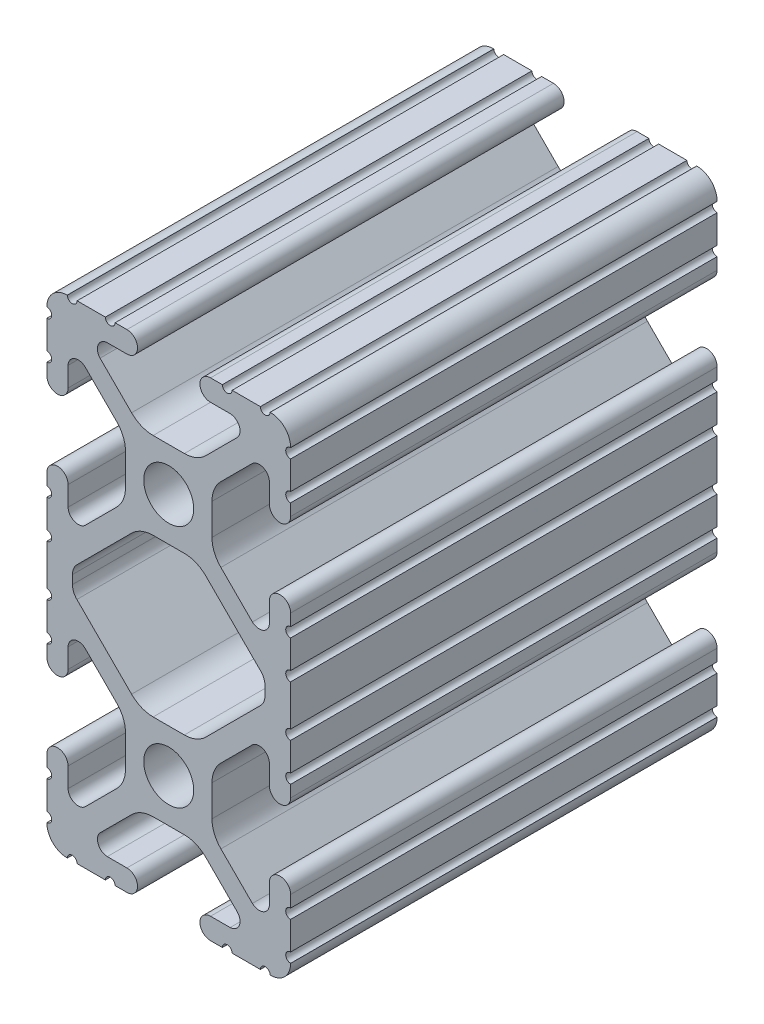
from build123d import *

# Parameters (mm, degrees)
SKETCH1_R      = 2.6035
EXTRUDE1_DEPTH = 44.45


with BuildPart() as part:
    # Sketch1 → Extrude1 (new body)
    with BuildSketch(Plane.XY):
        with BuildLine():
            Line((925.030031307, 602.850527299), (925.030031307, 605.796927299))
            ThreePointArc((925.030031307, 605.796927299), (924.522031307, 606.304927299), (925.030031307, 606.812927299))
            Line((925.030031307, 606.812927299), (925.030031307, 608.044827299))
            ThreePointArc((925.030031307, 608.044827299), (923.925131307, 609.149727299), (922.820231307, 608.044827299))
            Line((922.820231307, 608.044827299), (922.820231307, 605.99597822))
            ThreePointArc((922.820231307, 605.99597822), (922.173798087, 605.055266469), (921.048395335, 605.245747838))
            Line((921.048395335, 605.245747838), (917.764377722, 608.529666789))
            ThreePointArc((917.764377722, 608.529666789), (917.076099637, 609.559722614), (916.834408027, 610.774764544))
            Line((916.834408027, 610.774764544), (916.834408027, 614.027171862))
            ThreePointArc((916.834408027, 614.027171862), (917.076098205, 615.242210334), (917.764372429, 616.272264325))
            Line((917.764372429, 616.272264325), (921.048175959, 619.555984679))
            ThreePointArc((921.048175959, 619.555984679), (922.176497414, 619.74525718), (922.820231307, 618.799455901))
            Line((922.820231307, 618.799455901), (922.820231307, 616.757027299))
            ThreePointArc((922.820231307, 616.757027299), (923.925131307, 615.652127299), (925.030031307, 616.757027299))
            Line((925.030031307, 616.757027299), (925.030031307, 617.988927299))
            ThreePointArc((925.030031307, 617.988927299), (924.522031307, 618.496927299), (925.030031307, 619.004927299))
            Line((925.030031307, 619.004927299), (925.030031307, 621.951327299))
            ThreePointArc((925.030031307, 621.951327299), (924.522031307, 622.459327299), (925.030031307, 622.967327299))
            Line((925.030031307, 622.967327299), (925.030031307, 622.992727299))
            ThreePointArc((925.030031307, 622.992727299), (924.412553823, 624.483449815), (922.921831307, 625.100927299))
            Line((922.921831307, 625.100927299), (922.896431307, 625.100927299))
            ThreePointArc((922.896431307, 625.100927299), (922.388431307, 624.592927299), (921.880431307, 625.100927299))
            Line((921.880431307, 625.100927299), (918.934031307, 625.100927299))
            ThreePointArc((918.934031307, 625.100927299), (918.426031307, 624.592927299), (917.918031307, 625.100927299))
            Line((917.918031307, 625.100927299), (916.686131307, 625.100927299))
            ThreePointArc((916.686131307, 625.100927299), (915.581231307, 623.996027299), (916.686131307, 622.891127299))
            Line((916.686131307, 622.891127299), (918.734980386, 622.891127299))
            ThreePointArc((918.734980386, 622.891127299), (919.675692137, 622.244694079), (919.485210768, 621.119291326))
            Line((919.485210768, 621.119291326), (916.201291817, 617.835273713))
            ThreePointArc((916.201291817, 617.835273713), (915.171235992, 617.146995629), (913.956194062, 616.905304018))
            Line((913.956194062, 616.905304018), (910.703786744, 616.905304018))
            ThreePointArc((910.703786744, 616.905304018), (909.488748272, 617.146994197), (908.458694281, 617.835268421))
            Line((908.458694281, 617.835268421), (905.174973927, 621.11907195))
            ThreePointArc((905.174973927, 621.11907195), (904.985701426, 622.247393405), (905.931502705, 622.891127299))
            Line((905.931502705, 622.891127299), (907.973931307, 622.891127299))
            ThreePointArc((907.973931307, 622.891127299), (909.078831307, 623.996027299), (907.973931307, 625.100927299))
            Line((907.973931307, 625.100927299), (906.742031307, 625.100927299))
            ThreePointArc((906.742031307, 625.100927299), (906.234031307, 624.592927299), (905.726031307, 625.100927299))
            Line((905.726031307, 625.100927299), (902.779631307, 625.100927299))
            ThreePointArc((902.779631307, 625.100927299), (902.271631307, 624.592927299), (901.763631307, 625.100927299))
            Line((901.763631307, 625.100927299), (901.738231307, 625.100927299))
            ThreePointArc((901.738231307, 625.100927299), (900.247508791, 624.483449815), (899.630031307, 622.992727299))
            Line((899.630031307, 622.992727299), (899.630031307, 622.967327299))
            ThreePointArc((899.630031307, 622.967327299), (900.138031307, 622.459327299), (899.630031307, 621.951327299))
            Line((899.630031307, 621.951327299), (899.630031307, 619.004927299))
            ThreePointArc((899.630031307, 619.004927299), (900.138031307, 618.496927299), (899.630031307, 617.988927299))
            Line((899.630031307, 617.988927299), (899.630031307, 616.757027299))
            ThreePointArc((899.630031307, 616.757027299), (900.734931307, 615.652127299), (901.839831307, 616.757027299))
            Line((901.839831307, 616.757027299), (901.839831307, 618.805876378))
            ThreePointArc((901.839831307, 618.805876378), (902.486264527, 619.746588129), (903.61166728, 619.55610676))
            Line((903.61166728, 619.55610676), (906.895684893, 616.272187809))
            ThreePointArc((906.895684893, 616.272187809), (907.583962977, 615.242131983), (907.825654588, 614.027090054))
            Line((907.825654588, 614.027090054), (907.825654588, 610.774682736))
            ThreePointArc((907.825654588, 610.774682736), (907.583964409, 609.559644263), (906.895690185, 608.529590273))
            Line((906.895690185, 608.529590273), (903.611886656, 605.245869918))
            ThreePointArc((903.611886656, 605.245869918), (902.483565201, 605.056597418), (901.839831307, 606.002398697))
            Line((901.839831307, 606.002398697), (901.839831307, 608.044827299))
            ThreePointArc((901.839831307, 608.044827299), (900.734931307, 609.149727299), (899.630031307, 608.044827299))
            Line((899.630031307, 608.044827299), (899.630031307, 606.812927299))
            ThreePointArc((899.630031307, 606.812927299), (900.138031307, 606.304927299), (899.630031307, 605.796927299))
            Line((899.630031307, 605.796927299), (899.630031307, 602.850527299))
            ThreePointArc((899.630031307, 602.850527299), (900.138031307, 602.342527299), (899.630031307, 601.834527299))
            Line((899.630031307, 601.834527299), (899.630031307, 597.567327299))
            ThreePointArc((899.630031307, 597.567327299), (900.138031307, 597.059327299), (899.630031307, 596.551327299))
            Line((899.630031307, 596.551327299), (899.630031307, 593.604927299))
            ThreePointArc((899.630031307, 593.604927299), (900.138031307, 593.096927299), (899.630031307, 592.588927299))
            Line((899.630031307, 592.588927299), (899.630031307, 591.357027299))
            ThreePointArc((899.630031307, 591.357027299), (900.734931307, 590.252127299), (901.839831307, 591.357027299))
            Line((901.839831307, 591.357027299), (901.839831307, 593.405876378))
            ThreePointArc((901.839831307, 593.405876378), (902.486264527, 594.346588129), (903.61166728, 594.15610676))
            Line((903.61166728, 594.15610676), (906.895684893, 590.872187809))
            ThreePointArc((906.895684893, 590.872187809), (907.583962977, 589.842131983), (907.825654588, 588.627090054))
            Line((907.825654588, 588.627090054), (907.825654588, 585.374682736))
            ThreePointArc((907.825654588, 585.374682736), (907.583964409, 584.159644263), (906.895690185, 583.129590273))
            Line((906.895690185, 583.129590273), (903.611886656, 579.845869918))
            ThreePointArc((903.611886656, 579.845869918), (902.483565201, 579.656597418), (901.839831307, 580.602398697))
            Line((901.839831307, 580.602398697), (901.839831307, 582.644827299))
            ThreePointArc((901.839831307, 582.644827299), (900.734931307, 583.749727299), (899.630031307, 582.644827299))
            Line((899.630031307, 582.644827299), (899.630031307, 581.412927299))
            ThreePointArc((899.630031307, 581.412927299), (900.138031307, 580.904927299), (899.630031307, 580.396927299))
            Line((899.630031307, 580.396927299), (899.630031307, 577.450527299))
            ThreePointArc((899.630031307, 577.450527299), (900.138031307, 576.942527299), (899.630031307, 576.434527299))
            Line((899.630031307, 576.434527299), (899.630031307, 576.409127299))
            ThreePointArc((899.630031307, 576.409127299), (900.247508791, 574.918404783), (901.738231307, 574.300927299))
            Line((901.738231307, 574.300927299), (901.763631307, 574.300927299))
            ThreePointArc((901.763631307, 574.300927299), (902.271631307, 574.808927299), (902.779631307, 574.300927299))
            Line((902.779631307, 574.300927299), (905.726031307, 574.300927299))
            ThreePointArc((905.726031307, 574.300927299), (906.234031307, 574.808927299), (906.742031307, 574.300927299))
            Line((906.742031307, 574.300927299), (907.973931307, 574.300927299))
            ThreePointArc((907.973931307, 574.300927299), (909.078831307, 575.405827299), (907.973931307, 576.510727299))
            Line((907.973931307, 576.510727299), (905.925082228, 576.510727299))
            ThreePointArc((905.925082228, 576.510727299), (904.984370477, 577.157160519), (905.174851846, 578.282563271))
            Line((905.174851846, 578.282563271), (908.458770797, 581.566580884))
            ThreePointArc((908.458770797, 581.566580884), (909.488826623, 582.254858969), (910.703868552, 582.496550579))
            Line((910.703868552, 582.496550579), (913.95627587, 582.496550579))
            ThreePointArc((913.95627587, 582.496550579), (915.171314343, 582.254860401), (916.201368333, 581.566586177))
            Line((916.201368333, 581.566586177), (919.485088688, 578.282782647))
            ThreePointArc((919.485088688, 578.282782647), (919.674361188, 577.154461192), (918.728559909, 576.510727299))
            Line((918.728559909, 576.510727299), (916.686131307, 576.510727299))
            ThreePointArc((916.686131307, 576.510727299), (915.581231307, 575.405827299), (916.686131307, 574.300927299))
            Line((916.686131307, 574.300927299), (917.918031307, 574.300927299))
            ThreePointArc((917.918031307, 574.300927299), (918.426031307, 574.808927299), (918.934031307, 574.300927299))
            Line((918.934031307, 574.300927299), (921.880431307, 574.300927299))
            ThreePointArc((921.880431307, 574.300927299), (922.388431307, 574.808927299), (922.896431307, 574.300927299))
            Line((922.896431307, 574.300927299), (922.921831307, 574.300927299))
            ThreePointArc((922.921831307, 574.300927299), (924.412553823, 574.918404783), (925.030031307, 576.409127299))
            Line((925.030031307, 576.409127299), (925.030031307, 576.434527299))
            ThreePointArc((925.030031307, 576.434527299), (924.522031307, 576.942527299), (925.030031307, 577.450527299))
            Line((925.030031307, 577.450527299), (925.030031307, 580.396927299))
            ThreePointArc((925.030031307, 580.396927299), (924.522031307, 580.904927299), (925.030031307, 581.412927299))
            Line((925.030031307, 581.412927299), (925.030031307, 582.644827299))
            ThreePointArc((925.030031307, 582.644827299), (923.925131307, 583.749727299), (922.820231307, 582.644827299))
            Line((922.820231307, 582.644827299), (922.820231307, 580.59597822))
            ThreePointArc((922.820231307, 580.59597822), (922.173798087, 579.655266469), (921.048395335, 579.845747838))
            Line((921.048395335, 579.845747838), (917.764377722, 583.129666789))
            ThreePointArc((917.764377722, 583.129666789), (917.076099637, 584.159722614), (916.834408027, 585.374764544))
            Line((916.834408027, 585.374764544), (916.834408027, 588.627171862))
            ThreePointArc((916.834408027, 588.627171862), (917.076098205, 589.842210334), (917.764372429, 590.872264325))
            Line((917.764372429, 590.872264325), (921.048175959, 594.155984679))
            ThreePointArc((921.048175959, 594.155984679), (922.176497414, 594.34525718), (922.820231307, 593.399455901))
            Line((922.820231307, 593.399455901), (922.820231307, 591.357027299))
            ThreePointArc((922.820231307, 591.357027299), (923.925131307, 590.252127299), (925.030031307, 591.357027299))
            Line((925.030031307, 591.357027299), (925.030031307, 592.588927299))
            ThreePointArc((925.030031307, 592.588927299), (924.522031307, 593.096927299), (925.030031307, 593.604927299))
            Line((925.030031307, 593.604927299), (925.030031307, 596.551327299))
            ThreePointArc((925.030031307, 596.551327299), (924.522031307, 597.059327299), (925.030031307, 597.567327299))
            Line((925.030031307, 597.567327299), (925.030031307, 601.834527299))
            ThreePointArc((925.030031307, 601.834527299), (924.522031307, 602.342527299), (925.030031307, 602.850527299))
        make_face()
        with Locations((912.330031307, 612.400927299)):
            Circle(SKETCH1_R, mode=Mode.SUBTRACT)
        with Locations((912.330031307, 587.000927299)):
            Circle(SKETCH1_R, mode=Mode.SUBTRACT)
        with BuildLine():
            Line((902.297031307, 599.249379301), (902.297031307, 600.152366611))
            ThreePointArc((902.297031307, 600.152366611), (902.416901293, 600.755005552), (902.758262821, 601.265901642))
            Line((902.758262821, 601.265901642), (908.458770797, 606.966580884))
            ThreePointArc((908.458770797, 606.966580884), (909.488826623, 607.654858969), (910.703868552, 607.896550579))
            Line((910.703868552, 607.896550579), (913.95627587, 607.896550579))
            ThreePointArc((913.95627587, 607.896550579), (915.171314343, 607.654860401), (916.201368333, 606.966586177))
            Line((916.201368333, 606.966586177), (921.901797169, 601.266012953))
            ThreePointArc((921.901797169, 601.266012953), (922.243160611, 600.755115953), (922.363031307, 600.152475296))
            Line((922.363031307, 600.152475296), (922.363031307, 599.249487987))
            ThreePointArc((922.363031307, 599.249487987), (922.243161321, 598.646849046), (921.901799794, 598.135952956))
            Line((921.901799794, 598.135952956), (916.201291817, 592.435273713))
            ThreePointArc((916.201291817, 592.435273713), (915.171235992, 591.746995629), (913.956194062, 591.505304018))
            Line((913.956194062, 591.505304018), (910.703786744, 591.505304018))
            ThreePointArc((910.703786744, 591.505304018), (909.488748272, 591.746994197), (908.458694281, 592.435268421))
            Line((908.458694281, 592.435268421), (902.758265446, 598.135841645))
            ThreePointArc((902.758265446, 598.135841645), (902.416902003, 598.646738645), (902.297031307, 599.249379301))
        make_face(mode=Mode.SUBTRACT)
    extrude(amount=-EXTRUDE1_DEPTH)


solid = part.part
